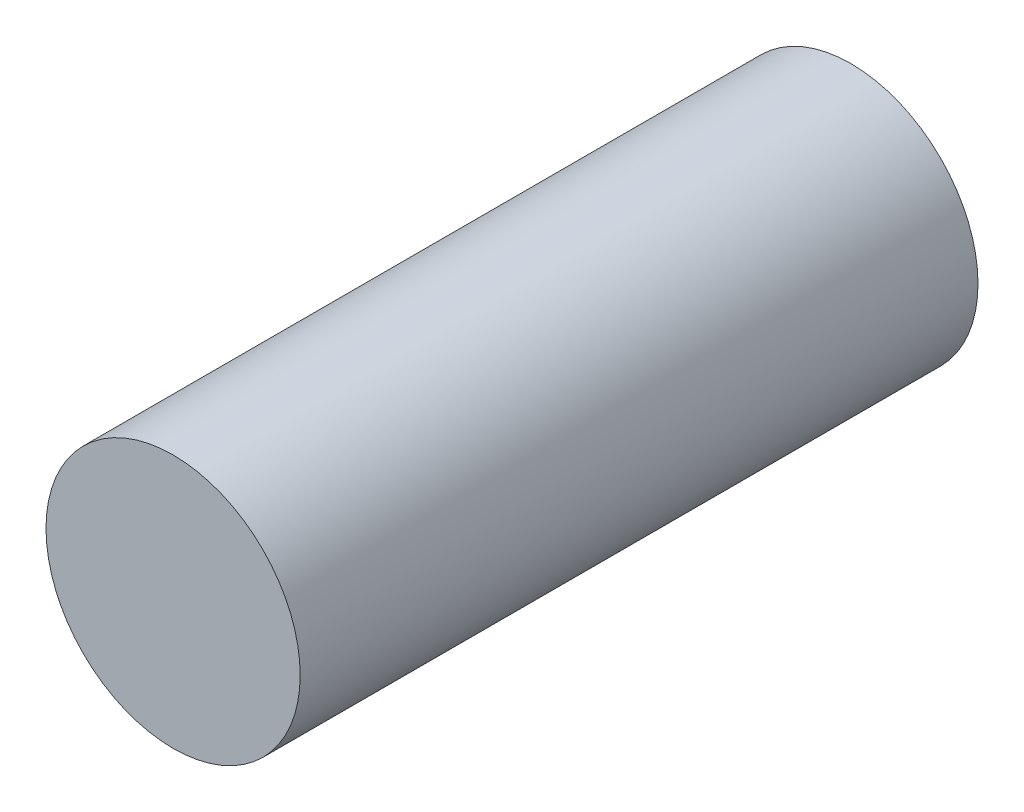
from build123d import *

# Parameters (mm, degrees)
CROQUIS1_R              = 10.5
SALIENTE_EXTRUIR1_DEPTH = 56


with BuildPart() as part:
    # Croquis1 → Saliente-Extruir1 (new body)
    with BuildSketch(Plane.XY):
        Circle(CROQUIS1_R)
    extrude(amount=SALIENTE_EXTRUIR1_DEPTH)


solid = part.part
